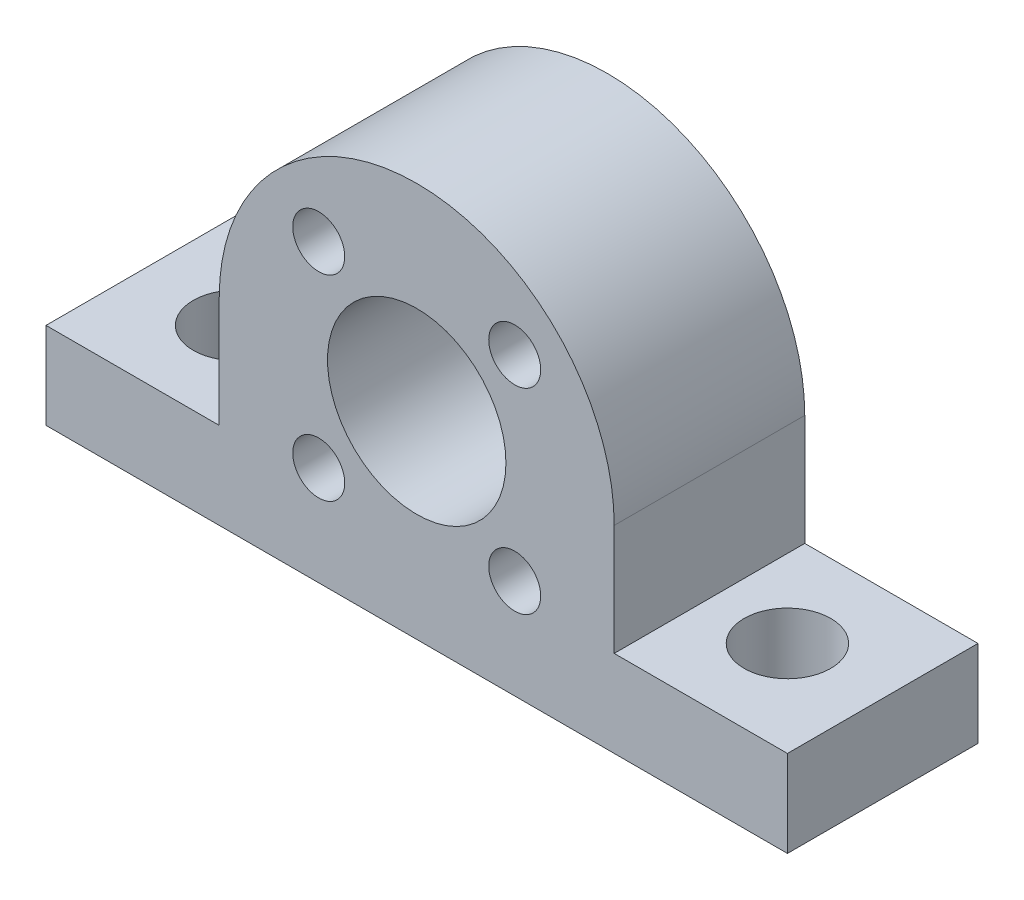
from build123d import *

# Parameters (mm, degrees)
SKETCH1_R           = 5.15
SKETCH1_R_2         = 1.5
BOSS_EXTRUDE1_DEPTH = 11
SKETCH2_R           = 2.5
CUT_EXTRUDE1_DEPTH  = 6


with BuildPart() as part:
    # Sketch1 → Boss-Extrude1 (new body)
    with BuildSketch(Plane.XY):
        with BuildLine():
            Line((-21.4, -6.4), (-11.4, -6.4))
            Line((-11.4, -6.4), (-11.4, 0))
            ThreePointArc((-11.4, 0), (0, 11.4), (11.4, 0))
            Line((11.4, 0), (11.4, -6.4))
            Line((11.4, -6.4), (21.4, -6.4))
            Line((21.4, -6.4), (21.4, -11.4))
            Line((21.4, -11.4), (-21.4, -11.4))
            Line((-21.4, -11.4), (-21.4, -6.4))
        make_face()
        Circle(SKETCH1_R, mode=Mode.SUBTRACT)
        with Locations((-5.656854249, 5.656854249)):
            Circle(SKETCH1_R_2, mode=Mode.SUBTRACT)
        with Locations((5.656854249, 5.656854249)):
            Circle(SKETCH1_R_2, mode=Mode.SUBTRACT)
        with Locations((-5.656854249, -5.656854249)):
            Circle(SKETCH1_R_2, mode=Mode.SUBTRACT)
        with Locations((5.656854249, -5.656854249)):
            Circle(SKETCH1_R_2, mode=Mode.SUBTRACT)
    extrude(amount=BOSS_EXTRUDE1_DEPTH)

    # Sketch2 → Cut-Extrude1 (cut, through all)
    with BuildSketch(Plane(origin=(0, -6.4, 0), x_dir=(1, 0, 0), z_dir=(0, 1, 0))):
        with Locations((-15.9, -5.5)):
            Circle(SKETCH2_R)
        with Locations((15.9, -5.5)):
            Circle(SKETCH2_R)
    extrude(amount=-CUT_EXTRUDE1_DEPTH, mode=Mode.SUBTRACT)


solid = part.part
